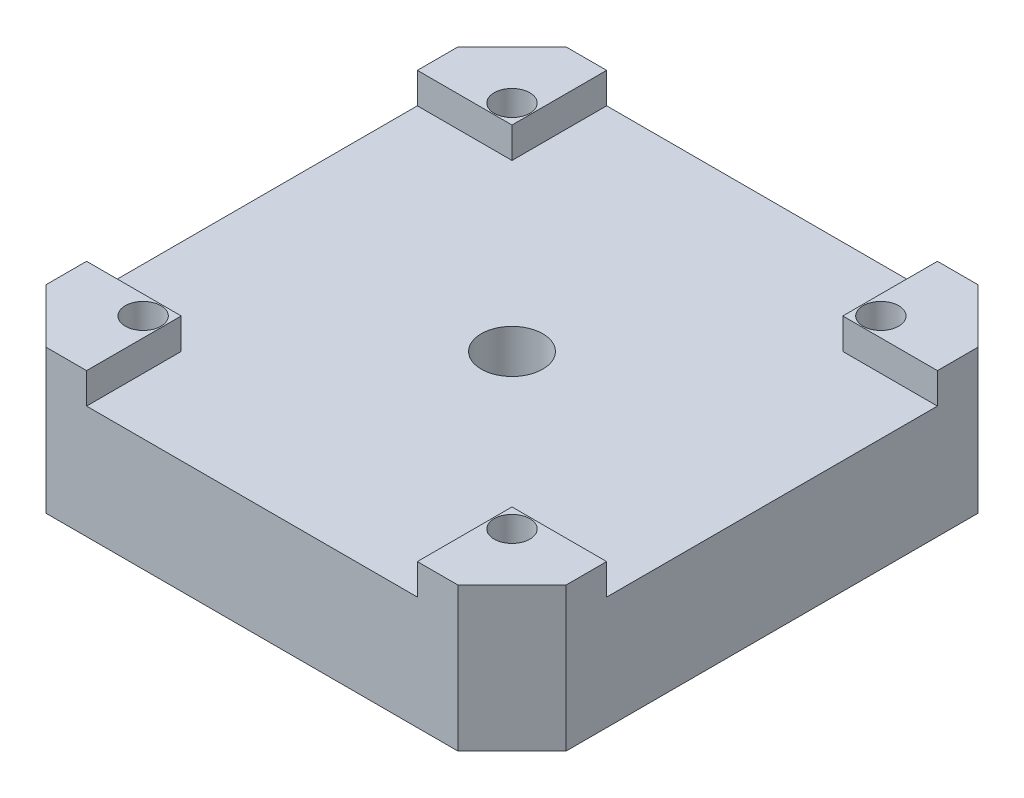
from build123d import *

# Parameters (mm, degrees)
BOSS_EXTRUDE1_DEPTH                                = 11.7
SKETCH12_W                                         = 26.901846944
SKETCH12_H                                         = 2.5
CUT_EXTRUDE6_DEPTH                                 = 43.3
SKETCH13_W                                         = 26.901846944
SKETCH13_H                                         = 2.5
CUT_EXTRUDE7_DEPTH                                 = 43.3
SKETCH14_R                                         = 3.25
CUT_EXTRUDE8_DEPTH                                 = 3
SKETCH15_R                                         = 2.5
CUT_EXTRUDE9_DEPTH                                 = 9.7
CBORE_FOR_M2_5_PAN_HEAD_MACHINE_SCREW1_D           = 2.9
CBORE_FOR_M2_5_PAN_HEAD_MACHINE_SCREW1_CBORE_D     = 6
CBORE_FOR_M2_5_PAN_HEAD_MACHINE_SCREW1_CBORE_DEPTH = 2.1


with BuildPart() as part:
    # Sketch1 → Boss-Extrude1 (new body)
    with BuildSketch(Plane(origin=(0, 0, 0), x_dir=(1, 0, 0), z_dir=(0, 1, 0))):
        Polygon((-21.15, 16.750923472), (-16.750923472, 21.15), (16.750923472, 21.15), (21.15, 16.750923472), (21.15, -16.750923472), (16.750923472, -21.15), (-16.750923472, -21.15), (-21.15, -16.750923472), align=None)
    extrude(amount=BOSS_EXTRUDE1_DEPTH)

    # Sketch12 → Cut-Extrude6 (cut, through all)
    with BuildSketch(Plane(origin=(21.15, 0, 0), x_dir=(0, 0, -1), z_dir=(1, 0, 0))):
        with Locations((0, 10.45)):
            Rectangle(SKETCH12_W, SKETCH12_H)
    extrude(amount=-CUT_EXTRUDE6_DEPTH, mode=Mode.SUBTRACT)

    # Sketch13 → Cut-Extrude7 (cut, through all)
    with BuildSketch(Plane.XY.offset(21.15)):
        with Locations((0, 10.45)):
            Rectangle(SKETCH13_W, SKETCH13_H)
    extrude(amount=-CUT_EXTRUDE7_DEPTH, mode=Mode.SUBTRACT)

    # Sketch14 → Cut-Extrude8 (cut)
    with BuildSketch(Plane.XZ):
        Circle(SKETCH14_R)
    extrude(amount=-CUT_EXTRUDE8_DEPTH, mode=Mode.SUBTRACT)

    # Sketch15 → Cut-Extrude9 (cut, through all)
    with BuildSketch(Plane.XZ.offset(-3)):
        Circle(SKETCH15_R)
    extrude(amount=-CUT_EXTRUDE9_DEPTH, mode=Mode.SUBTRACT)

    # CBORE for M2.5 Pan Head Machine Screw1 (through all)
    with Locations(Plane(origin=(0, 0, 0), x_dir=(-1, 0, 0), z_dir=(0, -1, 0))):
        with Locations((15, -15), (-15, -15), (-15, 15), (15, 15)):
            CounterBoreHole(CBORE_FOR_M2_5_PAN_HEAD_MACHINE_SCREW1_D / 2, CBORE_FOR_M2_5_PAN_HEAD_MACHINE_SCREW1_CBORE_D / 2, CBORE_FOR_M2_5_PAN_HEAD_MACHINE_SCREW1_CBORE_DEPTH)


solid = part.part
